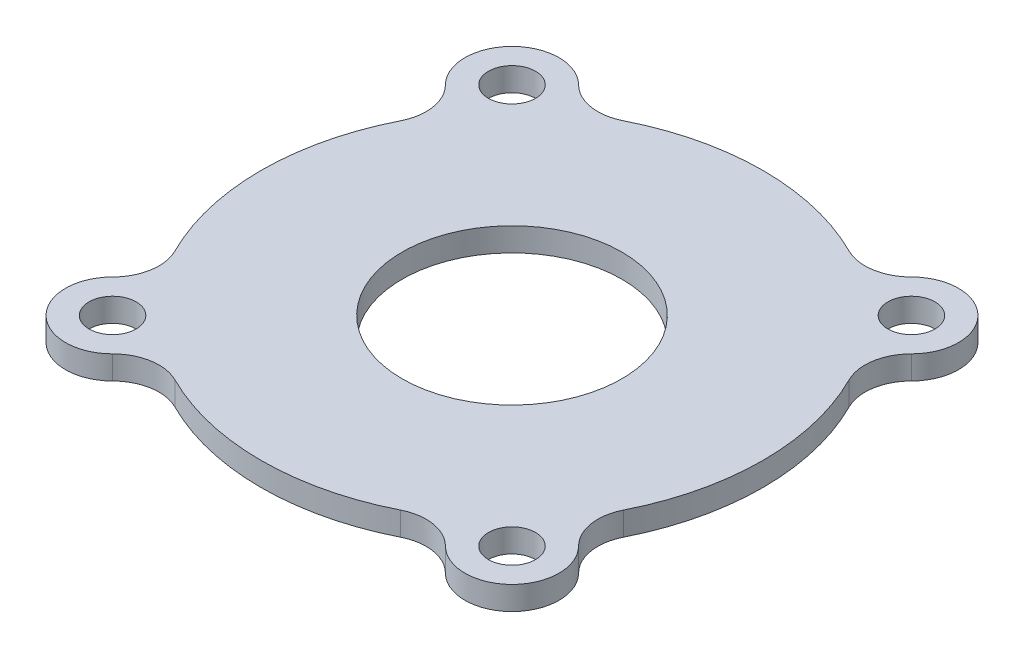
from build123d import *

# Parameters (mm, degrees)
SKETCH1_R           = 1.5
SKETCH1_R_2         = 7
BOSS_EXTRUDE1_DEPTH = 1.5
SKETCH1_3_R         = 13
SKETCH1_3_R_2       = 11
BOSS_EXTRUDE2_DEPTH = 1


with BuildPart() as part:
    # Sketch1 → Boss-Extrude1 (new body)
    with BuildSketch(Plane(origin=(0, 0, 0), x_dir=(1, 0, 0), z_dir=(0, 1, 0))):
        with BuildLine():
            ThreePointArc((14.849242405, 10.606601718), (14.849242405, 14.849242405), (10.606601718, 14.849242405))
            ThreePointArc((10.606601718, 14.849242405), (8.984050781, 14.019613784), (7.182942718, 14.297039341))
            ThreePointArc((7.182942718, 14.297039341), (0, 16), (-7.182942718, 14.297039341))
            ThreePointArc((-7.182942718, 14.297039341), (-8.984050781, 14.019613784), (-10.606601718, 14.849242405))
            ThreePointArc((-10.606601718, 14.849242405), (-14.849242405, 14.849242405), (-14.849242405, 10.606601718))
            ThreePointArc((-14.849242405, 10.606601718), (-14.019613784, 8.984050781), (-14.297039341, 7.182942718))
            ThreePointArc((-14.297039341, 7.182942718), (-16, 0), (-14.297039341, -7.182942718))
            ThreePointArc((-14.297039341, -7.182942718), (-14.019613784, -8.984050781), (-14.849242405, -10.606601718))
            ThreePointArc((-14.849242405, -10.606601718), (-14.849242405, -14.849242405), (-10.606601718, -14.849242405))
            ThreePointArc((-10.606601718, -14.849242405), (-8.984050781, -14.019613784), (-7.182942718, -14.297039341))
            ThreePointArc((-7.182942718, -14.297039341), (0, -16), (7.182942718, -14.297039341))
            ThreePointArc((7.182942718, -14.297039341), (8.984050781, -14.019613784), (10.606601718, -14.849242405))
            ThreePointArc((10.606601718, -14.849242405), (14.849242405, -14.849242405), (14.849242405, -10.606601718))
            ThreePointArc((14.849242405, -10.606601718), (14.019613784, -8.984050781), (14.297039341, -7.182942718))
            ThreePointArc((14.297039341, -7.182942718), (16, 0), (14.297039341, 7.182942718))
            ThreePointArc((14.297039341, 7.182942718), (14.019613784, 8.984050781), (14.849242405, 10.606601718))
        make_face()
        with Locations((12.727922061, 12.727922061)):
            Circle(SKETCH1_R, mode=Mode.SUBTRACT)
        with Locations((12.727922061, -12.727922061)):
            Circle(SKETCH1_R, mode=Mode.SUBTRACT)
        with Locations((-12.727922061, -12.727922061)):
            Circle(SKETCH1_R, mode=Mode.SUBTRACT)
        with Locations((-12.727922061, 12.727922061)):
            Circle(SKETCH1_R, mode=Mode.SUBTRACT)
        Circle(SKETCH1_R_2, mode=Mode.SUBTRACT)
    extrude(amount=BOSS_EXTRUDE1_DEPTH)

    # Sketch1_3 → Boss-Extrude2 (add)
    with BuildSketch(Plane(origin=(0, 0, 0), x_dir=(1, 0, 0), z_dir=(0, 1, 0))):
        Circle(SKETCH1_3_R)
        Circle(SKETCH1_3_R_2, mode=Mode.SUBTRACT)
    extrude(amount=-BOSS_EXTRUDE2_DEPTH)


solid = part.part
